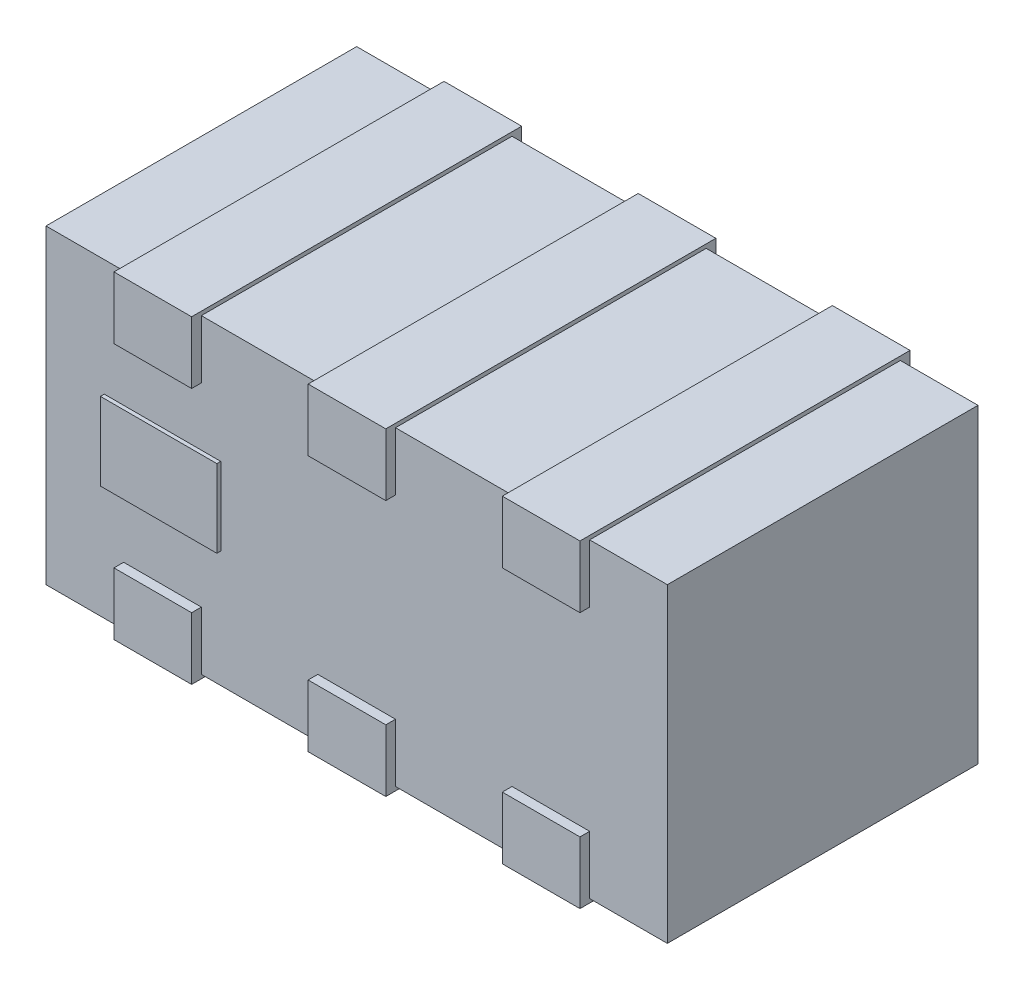
from build123d import *

# Parameters (mm, degrees)
SKETCH_1_W      = 1.6
SKETCH_1_H      = 0.8
EXTRUDE_1_DEPTH = 0.8
EXTRUDE_START   = -0.15
SKETCH_2_W      = 0.2
SKETCH_2_H      = 0.85
EXTRUDE_2_DEPTH = 0.16
SKETCH_3_W      = 0.2
SKETCH_3_H      = 0.85
EXTRUDE_3_DEPTH = 0.16
SKETCH_4_W      = 0.3
SKETCH_4_H      = 0.2
EXTRUDE_4_DEPTH = 0.01


with BuildPart() as part:
    # Эскиз1 → Бобышка-Вытянуть1 (new body)
    with BuildSketch(Plane(origin=(0, 0, 0), x_dir=(1, 0, 0), z_dir=(0, 1, 0))):
        Rectangle(SKETCH_1_W, SKETCH_1_H)
    extrude(amount=EXTRUDE_1_DEPTH)

    # Эскиз2 → Бобышка-Вытянуть2 (add)
    with BuildSketch(Plane(origin=(0, 0.8, 0), x_dir=(1, 0, 0), z_dir=(0, 1, 0)).offset(EXTRUDE_START)):
        with Locations((-0.5, 0)):
            Rectangle(SKETCH_2_W, SKETCH_2_H)
        Rectangle(SKETCH_2_W, SKETCH_2_H)
        with Locations((0.5, 0)):
            Rectangle(SKETCH_2_W, SKETCH_2_H)
    extrude(amount=EXTRUDE_2_DEPTH)

    # Эскиз3 → Бобышка-Вытянуть3 (add)
    with BuildSketch(Plane.XZ.offset(EXTRUDE_START)):
        with Locations((-0.5, 0)):
            Rectangle(SKETCH_3_W, SKETCH_3_H)
        Rectangle(SKETCH_3_W, SKETCH_3_H)
        with Locations((0.5, 0)):
            Rectangle(SKETCH_3_W, SKETCH_3_H)
    extrude(amount=EXTRUDE_3_DEPTH)

    # Эскиз4 → Бобышка-Вытянуть4 (add)
    with BuildSketch(Plane.XY.offset(0.4)):
        with Locations((-0.5, 0.4)):
            Rectangle(SKETCH_4_W, SKETCH_4_H)
    extrude(amount=EXTRUDE_4_DEPTH)


solid = part.part
